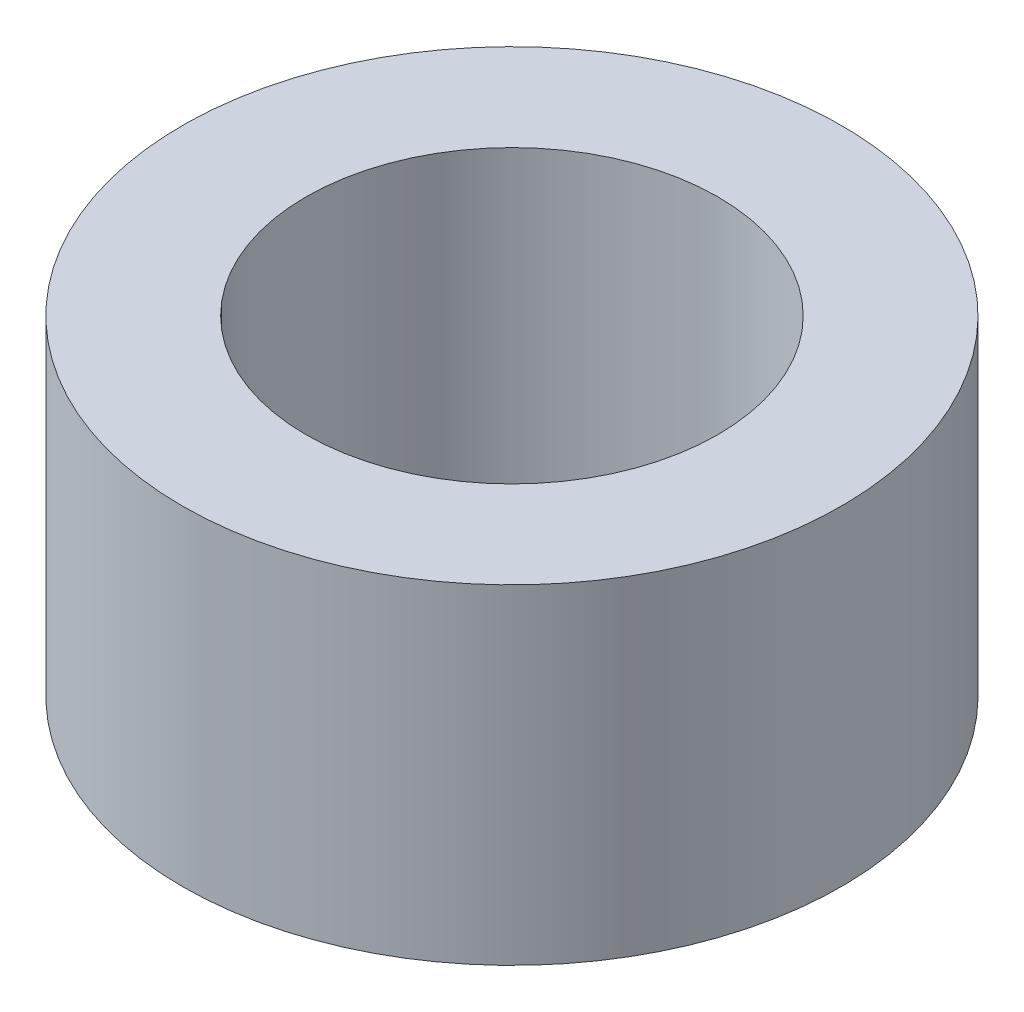
from build123d import *

# Parameters (mm, degrees)
SKETCH1_R           = 5
SKETCH1_R_2         = 3.125
BOSS_EXTRUDE1_DEPTH = 5


with BuildPart() as part:
    # Sketch1 → Boss-Extrude1 (new body)
    with BuildSketch(Plane(origin=(0, 0, 0), x_dir=(1, 0, 0), z_dir=(0, 1, 0))):
        Circle(SKETCH1_R)
        Circle(SKETCH1_R_2, mode=Mode.SUBTRACT)
    extrude(amount=BOSS_EXTRUDE1_DEPTH)


solid = part.part
